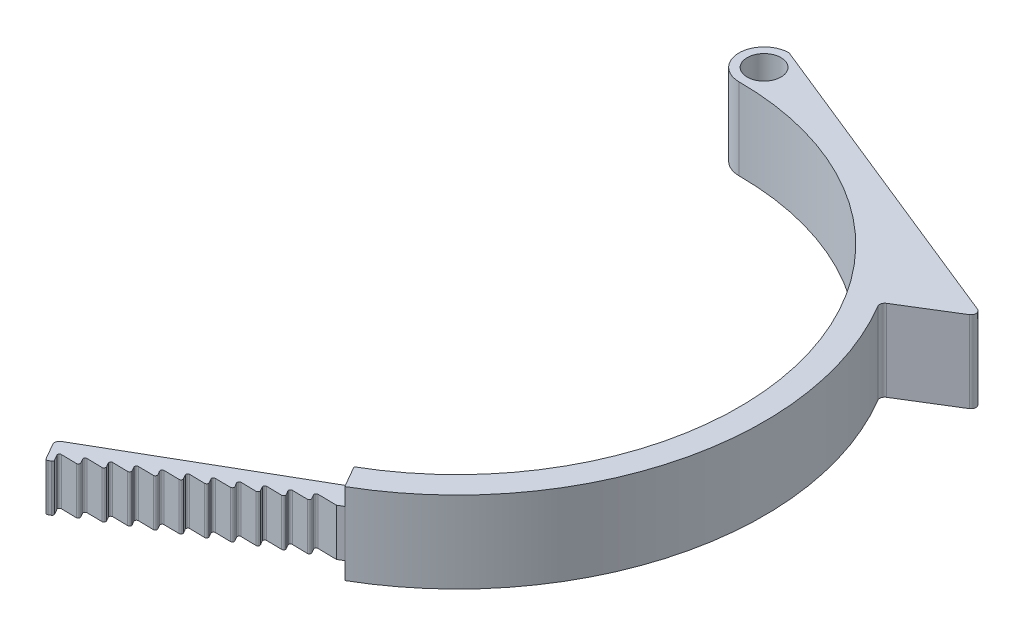
from build123d import *

# Parameters (mm, degrees)
BOSS_EXTRUDE1_DEPTH = 13
CUT_EXTRUDE3_DEPTH  = 14
FILLET2_R           = 0.3
FILLET1_R           = 0.8
SKETCH3_OUTSIDE_W   = 154.491
SKETCH3_OUTSIDE_H   = 40.548
SKETCH3_OUTSIDE_W_2 = 5.910380326
SKETCH3_OUTSIDE_H_2 = 7.5
CUT_EXTRUDE2_DEPTH  = 35


with BuildPart() as part:
    # Sketch1 → Boss-Extrude1 (new body)
    with BuildSketch(Plane(origin=(0, 0, 0), x_dir=(1, 0, 0), z_dir=(0, 1, 0))):
        with BuildLine():
            Line((0, 51.7), (0, 53))
            ThreePointArc((0, 53), (-4, 49), (0, 45))
            ThreePointArc((0, 45), (43.466662183, 11.64685703), (22.5, -38.97114317))
            Line((22.5, -38.97114317), (-7.810889132, -56.47114317))
            Line((-7.810889132, -56.47114317), (-5.810889132, -59.935244785))
            Line((-5.810889132, -59.935244785), (24.5, -42.435244785))
            ThreePointArc((24.5, -42.435244785), (47.509263839, -11.994575836), (41.707047143, 25.720074234))
            ThreePointArc((41.707047143, 25.720074234), (25.051905135, 42.111780407), (2.698975076, 48.925612245))
            ThreePointArc((2.698975076, 48.925612245), (-1.935309657, 47.117295421), (0, 51.7))
        make_face()
        with BuildLine():
            Line((51.921017872, 32.018867925), (0, 53))
            Line((0, 53), (0, 51.7))
            ThreePointArc((0, 51.7), (1.909188309, 50.909188309), (2.7, 49))
            ThreePointArc((2.7, 49), (2.699743757, 48.962802592), (2.698975076, 48.925612245))
            ThreePointArc((2.698975076, 48.925612245), (25.051905135, 42.111780407), (41.707047143, 25.720074234))
            Line((41.707047143, 25.720074234), (51.921017872, 32.018867925))
        make_face()
    extrude(amount=BOSS_EXTRUDE1_DEPTH)

    # Sketch2 → Cut-Extrude3 (cut, through all)
    with BuildSketch(Plane(origin=(0, 13, 0), x_dir=(1, 0, 0), z_dir=(0, 1, 0))):
        Polygon((-5.844863729, -57.876399059), (-4.944863729, -59.435244785), (-2.346787517, -57.935244785), align=None)
        Polygon((-3.246787517, -56.376399059), (-2.346787517, -57.935244785), (0.251288694, -56.435244785), align=None)
        Polygon((-0.648711306, -54.876399059), (0.251288694, -56.435244785), (2.849364905, -54.935244785), align=None)
        Polygon((1.949364905, -53.376399059), (2.849364905, -54.935244785), (5.447441117, -53.435244785), align=None)
        Polygon((4.547441117, -51.876399059), (5.447441117, -53.435244785), (8.045517328, -51.935244785), align=None)
        Polygon((7.145517328, -50.376399059), (8.045517328, -51.935244785), (10.643593539, -50.435244785), align=None)
        Polygon((9.743593539, -48.876399059), (10.643593539, -50.435244785), (13.241669751, -48.935244785), align=None)
        Polygon((12.341669751, -47.376399059), (13.241669751, -48.935244785), (15.839745962, -47.435244785), align=None)
        Polygon((14.939745962, -45.876399059), (15.839745962, -47.435244785), (18.437822174, -45.935244785), align=None)
        Polygon((17.537822174, -44.376399059), (18.437822174, -45.935244785), (21.035898385, -44.435244785), align=None)
        Polygon((20.135898385, -42.876399059), (21.035898385, -44.435244785), (23.633974596, -42.935244785), align=None)
    extrude(amount=-CUT_EXTRUDE3_DEPTH, mode=Mode.SUBTRACT)

    # Fillet2
    fillet2_edges = [part.edges().sort_by_distance(p)[0] for p in [
        (-3.246787517, 6.5, 56.376399059),
        (0.251288694, 6.5, 56.435244785),
        (1.949364905, 6.5, 53.376399059),
        (5.447441117, 6.5, 53.435244785),
        (7.145517328, 6.5, 50.376399059),
        (10.643593539, 6.5, 50.435244785),
        (12.341669751, 6.5, 47.376399059),
        (15.839745962, 6.5, 47.435244785),
        (17.537822174, 6.5, 44.376399059),
        (21.035898385, 6.5, 44.435244785),
        (-5.810889132, 6.5, 59.935244785),
        (-5.844863729, 6.5, 57.876399059),
        (-2.346787517, 6.5, 57.935244785),
        (-4.944863729, 6.5, 59.435244785),
        (-0.648711306, 6.5, 54.876399059),
        (2.849364905, 6.5, 54.935244785),
        (4.547441117, 6.5, 51.876399059),
        (8.045517328, 6.5, 51.935244785),
        (9.743593539, 6.5, 48.876399059),
        (13.241669751, 6.5, 48.935244785),
        (14.939745962, 6.5, 45.876399059),
        (18.437822174, 6.5, 45.935244785),
        (20.135898385, 6.5, 42.876399059),
    ]]
    fillet(fillet2_edges, radius=FILLET2_R)

    # Fillet1
    fillet1_edges = [part.edges().sort_by_distance(p)[0] for p in [
        (51.921017872, 6.5, -32.018867925),
        (41.707047143, 6.5, -25.720074234),
        (-7.810889132, 6.5, 56.47114317),
        (0, 6.5, -53),
    ]]
    fillet(fillet1_edges, radius=FILLET1_R)

    # Sketch3 outside → Cut-Extrude2 (cut)
    with BuildSketch(Plane(origin=(-30.310889132, 0, 17.5), x_dir=(0.5, 0, 0.866025404), z_dir=(-0.866025404, 0, 0.5))):
        with Locations((13.8165, 6.5)):
            Rectangle(SKETCH3_OUTSIDE_W, SKETCH3_OUTSIDE_H)
        with Locations((47.141631591, 6.5)):
            Rectangle(SKETCH3_OUTSIDE_W_2, SKETCH3_OUTSIDE_H_2, mode=Mode.SUBTRACT)
    extrude(amount=-CUT_EXTRUDE2_DEPTH, mode=Mode.SUBTRACT)


solid = part.part
